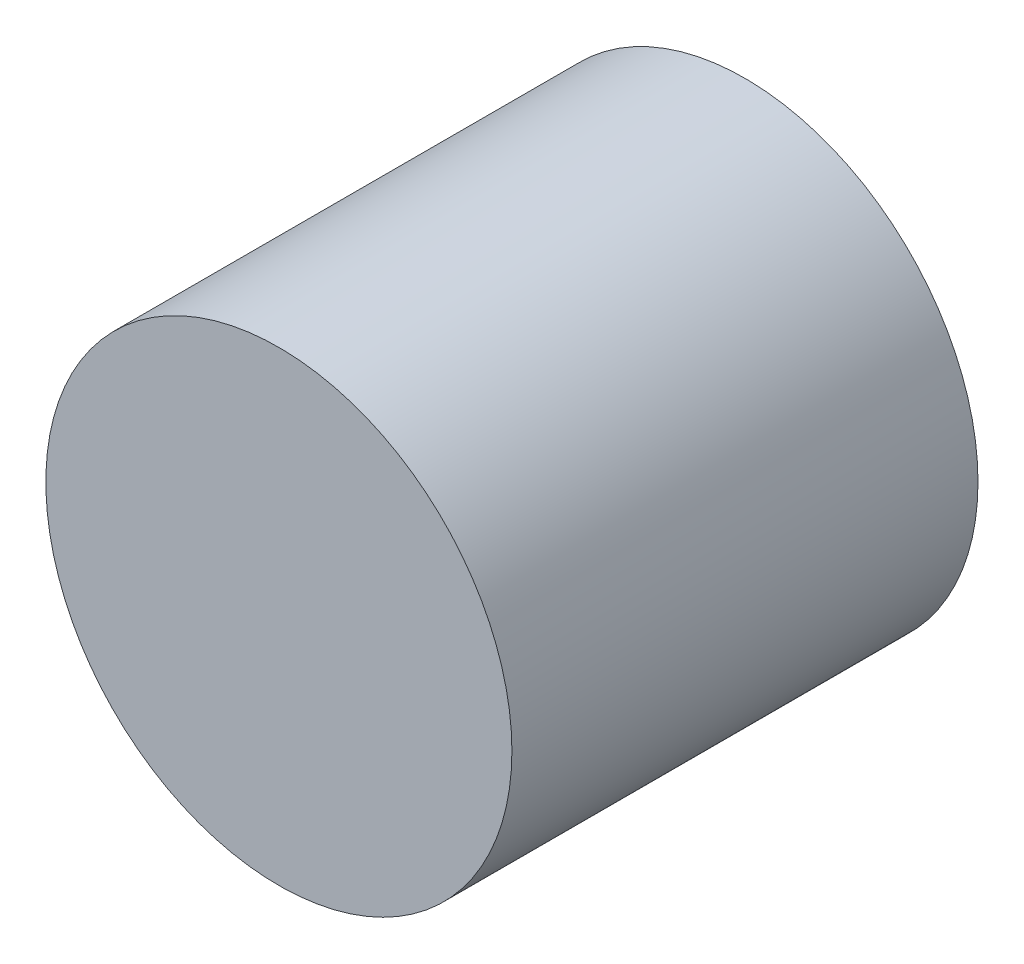
from build123d import *

# Parameters (mm, degrees)
SKETCH1_R           = 2.5
BOSS_EXTRUDE1_DEPTH = 5


with BuildPart() as part:
    # Sketch1 → Boss-Extrude1 (new body)
    with BuildSketch(Plane.XY):
        Circle(SKETCH1_R)
    extrude(amount=BOSS_EXTRUDE1_DEPTH)


solid = part.part
